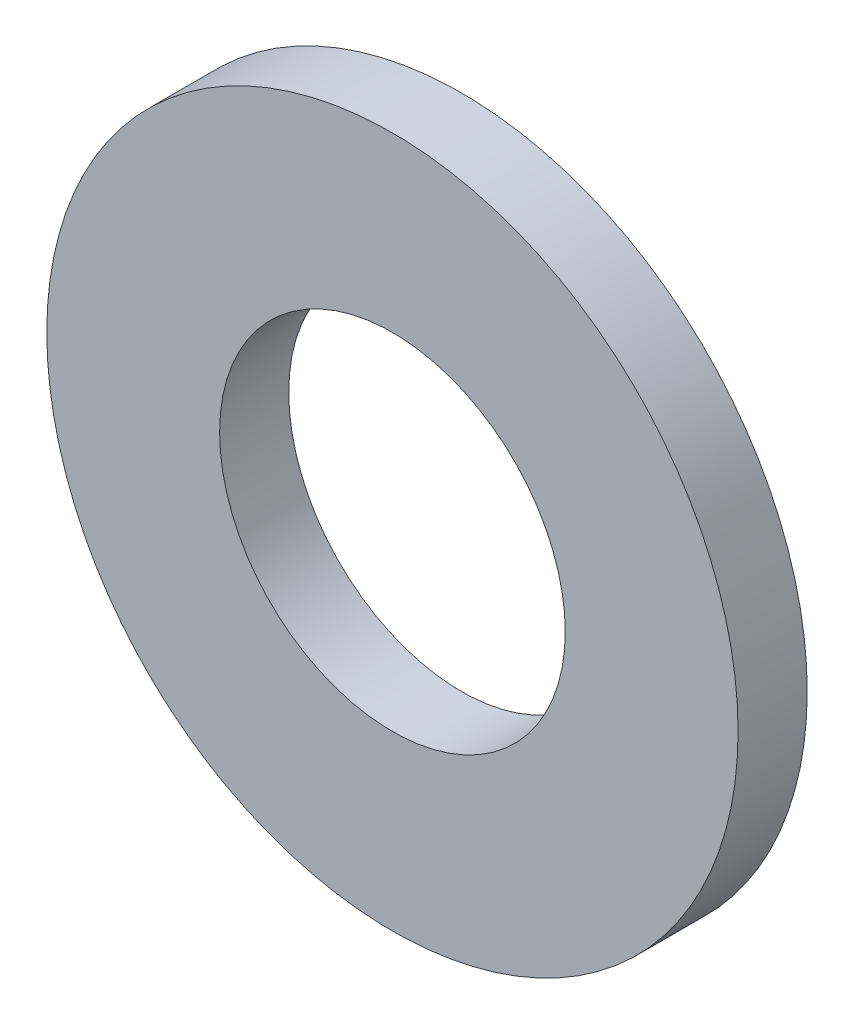
from build123d import *

# Parameters (mm, degrees)
ESQUISSE1_R        = 10
ESQUISSE1_R_2      = 5
BOSS_EXTRU_1_DEPTH = 2


with BuildPart() as part:
    # Esquisse1 → Boss.-Extru.1 (new body)
    with BuildSketch(Plane.XY):
        Circle(ESQUISSE1_R)
        Circle(ESQUISSE1_R_2, mode=Mode.SUBTRACT)
    extrude(amount=BOSS_EXTRU_1_DEPTH)


solid = part.part
